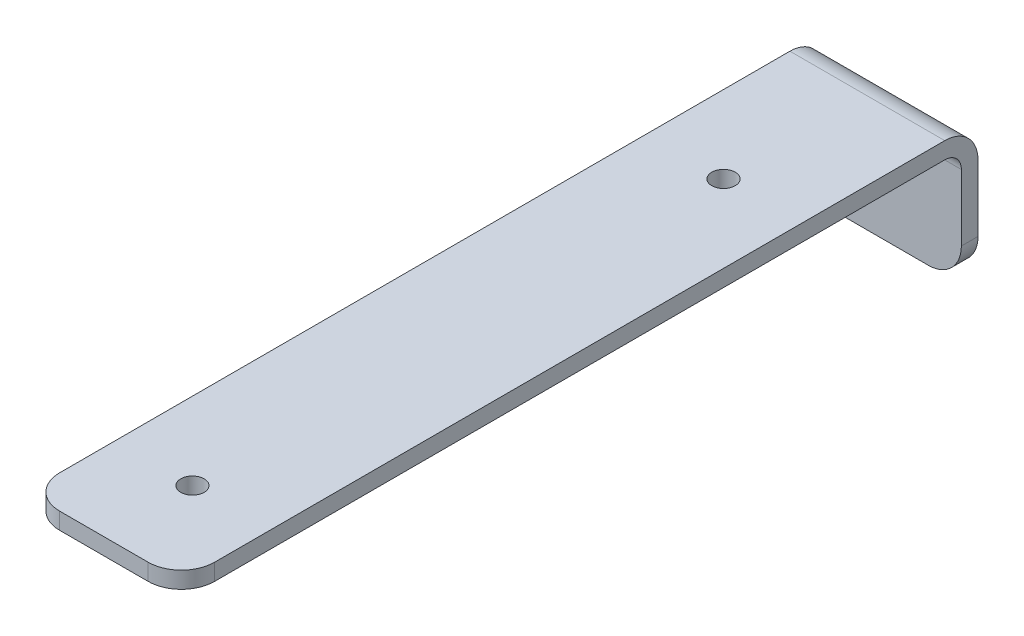
from build123d import *

# Parameters (mm, degrees)
BOSS_EXTRUDE1_DEPTH = 44.45
FILLET1_R           = 4.7752
FILLET2_R           = 9.525
FILLET3_R           = 9.525
SKETCH2_R           = 3.3655
CUT_EXTRUDE1_DEPTH  = 39.1


with BuildPart() as part:
    # Sketch1 → Boss-Extrude1 (new body)
    with BuildSketch(Plane(origin=(0, 0, 0), x_dir=(0, 0, -1), z_dir=(1, 0, 0))):
        Polygon((0, 0), (0, 33.3248), (-223.8248, 33.3248), (-223.8248, 38.1), (4.7752, 38.1), (4.7752, 0), align=None)
    extrude(amount=BOSS_EXTRUDE1_DEPTH)

    # Fillet1
    fillet1_edges = [part.edges().sort_by_distance(p)[0] for p in [
        (22.225, 33.3248, 0),
    ]]
    fillet(fillet1_edges, radius=FILLET1_R)

    # Fillet2
    fillet2_edges = [part.edges().sort_by_distance(p)[0] for p in [
        (22.225, 38.1, -4.7752),
    ]]
    fillet(fillet2_edges, radius=FILLET2_R)

    # Fillet3
    fillet3_edges = [part.edges().sort_by_distance(p)[0] for p in [
        (44.45, 35.7124, 223.8248),
        (44.45, 0, -2.3876),
        (0, 35.7124, 223.8248),
        (0, 0, -2.3876),
    ]]
    fillet(fillet3_edges, radius=FILLET3_R)

    # Sketch2 → Cut-Extrude1 (cut, through all)
    with BuildSketch(Plane(origin=(0, 38.1, 0), x_dir=(1, 0, 0), z_dir=(0, 1, 0))):
        with Locations((22.225, -198.4248)):
            Circle(SKETCH2_R)
        with Locations((22.225, -46.0248)):
            Circle(SKETCH2_R)
    extrude(amount=-CUT_EXTRUDE1_DEPTH, mode=Mode.SUBTRACT)


solid = part.part
